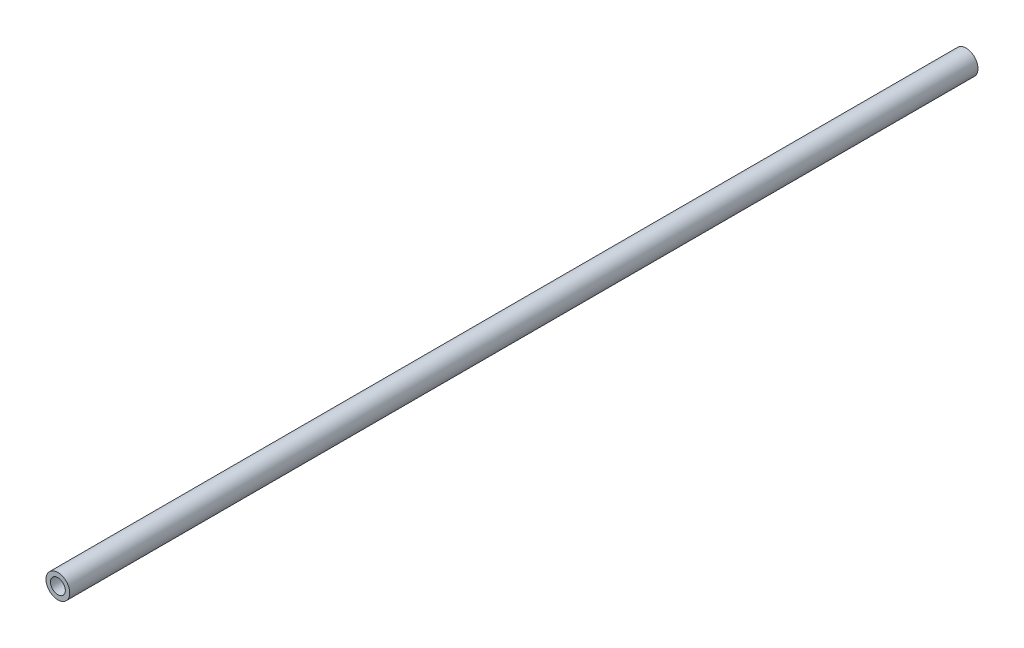
from build123d import *

# Parameters (mm, degrees)
SKETCH1_R           = 8.55
SKETCH1_R_2         = 5.35
BOSS_EXTRUDE1_DEPTH = 653.17


with BuildPart() as part:
    # Sketch1 → Boss-Extrude1 (new body)
    with BuildSketch(Plane.XY):
        Circle(SKETCH1_R)
        Circle(SKETCH1_R_2, mode=Mode.SUBTRACT)
    extrude(amount=-BOSS_EXTRUDE1_DEPTH)


solid = part.part
